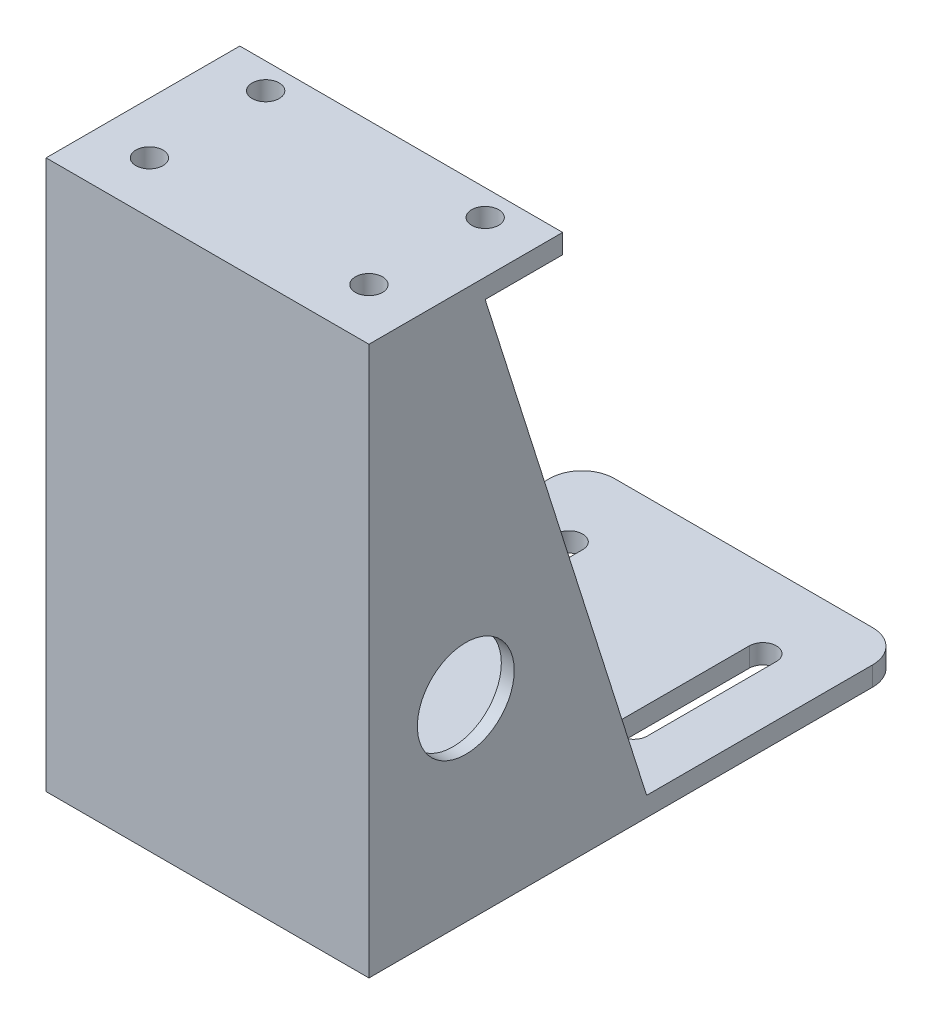
from build123d import *

# Parameters (mm, degrees)
EXTRUDE_1_DEPTH     = 25
EXTRUDE_2_DEPTH     = 2
CUT_EXTRUDE_1_REACH = 87
SKETCH_4_R          = 2.1
CUT_EXTRUDE_2_REACH = 87
FILLET_1_R          = 5
EXTRUDE_3_DEPTH     = 2
SKETCH_7_R          = 7.5
CUT_EXTRUDE_3_DEPTH = 51


with BuildPart() as part:
    # 草图1 → 凸台-拉伸1 (new body, symmetric)
    with BuildSketch(Plane(origin=(0, 0, 0), x_dir=(0, 0, -1), z_dir=(1, 0, 0))):
        Polygon((0, 0), (0, 85), (30, 85), (30, 82), (3, 82), (3, 3), (83, 3), (83, 0), align=None)
    extrude(amount=EXTRUDE_1_DEPTH, both=True)

    # 草图2 → 凸台-拉伸2 (add)
    with BuildSketch(Plane(origin=(25, 0, 0), x_dir=(0, 0, -1), z_dir=(1, 0, 0))):
        Polygon((43, 3), (3, 3), (3, 82), (18, 82), align=None)
    extrude(amount=-EXTRUDE_2_DEPTH)

    # 草图4 → 切除-拉伸1 (cut, up to next)
    with BuildSketch(Plane(origin=(0, 85, 0), x_dir=(1, 0, 0), z_dir=(0, 1, 0)), mode=Mode.PRIVATE) as cut_extrude_1_sk1:
        with Locations((-17, 26)):
            Circle(SKETCH_4_R)
    cut_extrude_1_tool1 = extrude(cut_extrude_1_sk1.sketch, amount=-CUT_EXTRUDE_1_REACH, mode=Mode.PRIVATE) & part.part
    add(cut_extrude_1_tool1.solids().sort_by_distance((-17, 85, -26))[0], mode=Mode.SUBTRACT)
    # 草图4 → 切除-拉伸1 (cut, up to next)
    with BuildSketch(Plane(origin=(0, 85, 0), x_dir=(1, 0, 0), z_dir=(0, 1, 0)), mode=Mode.PRIVATE) as cut_extrude_1_sk2:
        with Locations((-17, 8)):
            Circle(SKETCH_4_R)
    cut_extrude_1_tool2 = extrude(cut_extrude_1_sk2.sketch, amount=-CUT_EXTRUDE_1_REACH, mode=Mode.PRIVATE) & part.part
    add(cut_extrude_1_tool2.solids().sort_by_distance((-17, 85, -8))[0], mode=Mode.SUBTRACT)
    # 草图4 → 切除-拉伸1 (cut, up to next)
    with BuildSketch(Plane(origin=(0, 85, 0), x_dir=(1, 0, 0), z_dir=(0, 1, 0)), mode=Mode.PRIVATE) as cut_extrude_1_sk3:
        with Locations((17, 8)):
            Circle(SKETCH_4_R)
    cut_extrude_1_tool3 = extrude(cut_extrude_1_sk3.sketch, amount=-CUT_EXTRUDE_1_REACH, mode=Mode.PRIVATE) & part.part
    add(cut_extrude_1_tool3.solids().sort_by_distance((17, 85, -8))[0], mode=Mode.SUBTRACT)
    # 草图4 → 切除-拉伸1 (cut, up to next)
    with BuildSketch(Plane(origin=(0, 85, 0), x_dir=(1, 0, 0), z_dir=(0, 1, 0)), mode=Mode.PRIVATE) as cut_extrude_1_sk4:
        with Locations((17, 26)):
            Circle(SKETCH_4_R)
    cut_extrude_1_tool4 = extrude(cut_extrude_1_sk4.sketch, amount=-CUT_EXTRUDE_1_REACH, mode=Mode.PRIVATE) & part.part
    add(cut_extrude_1_tool4.solids().sort_by_distance((17, 85, -26))[0], mode=Mode.SUBTRACT)

    # 草图5 → 切除-拉伸2 (cut, up to next)
    with BuildSketch(Plane.XZ, mode=Mode.PRIVATE) as cut_extrude_2_sk1:
        with BuildLine():
            Line((-12.9, -11), (-12.9, -31))
            ThreePointArc((-12.9, -31), (-15, -33.1), (-17.1, -31))
            Line((-17.1, -31), (-17.1, -11))
            ThreePointArc((-17.1, -11), (-15, -8.9), (-12.9, -11))
        make_face()
    cut_extrude_2_tool1 = extrude(cut_extrude_2_sk1.sketch, amount=-CUT_EXTRUDE_2_REACH, mode=Mode.PRIVATE) & part.part
    add(cut_extrude_2_tool1.solids().sort_by_distance((-15, 0, -21))[0], mode=Mode.SUBTRACT)
    # 草图5 → 切除-拉伸2 (cut, up to next)
    with BuildSketch(Plane.XZ, mode=Mode.PRIVATE) as cut_extrude_2_sk2:
        with BuildLine():
            Line((-12.9, -51), (-12.9, -71))
            ThreePointArc((-12.9, -71), (-15, -73.1), (-17.1, -71))
            Line((-17.1, -71), (-17.1, -51))
            ThreePointArc((-17.1, -51), (-15, -48.9), (-12.9, -51))
        make_face()
    cut_extrude_2_tool2 = extrude(cut_extrude_2_sk2.sketch, amount=-CUT_EXTRUDE_2_REACH, mode=Mode.PRIVATE) & part.part
    add(cut_extrude_2_tool2.solids().sort_by_distance((-15, 0, -61))[0], mode=Mode.SUBTRACT)
    # 草图5 → 切除-拉伸2 (cut, up to next)
    with BuildSketch(Plane.XZ, mode=Mode.PRIVATE) as cut_extrude_2_sk3:
        with BuildLine():
            Line((12.9, -51), (12.9, -71))
            ThreePointArc((12.9, -71), (15, -73.1), (17.1, -71))
            Line((17.1, -71), (17.1, -51))
            ThreePointArc((17.1, -51), (15, -48.9), (12.9, -51))
        make_face()
    cut_extrude_2_tool3 = extrude(cut_extrude_2_sk3.sketch, amount=-CUT_EXTRUDE_2_REACH, mode=Mode.PRIVATE) & part.part
    add(cut_extrude_2_tool3.solids().sort_by_distance((15, 0, -61))[0], mode=Mode.SUBTRACT)
    # 草图5 → 切除-拉伸2 (cut, up to next)
    with BuildSketch(Plane.XZ, mode=Mode.PRIVATE) as cut_extrude_2_sk4:
        with BuildLine():
            Line((12.9, -11), (12.9, -31))
            ThreePointArc((12.9, -31), (15, -33.1), (17.1, -31))
            Line((17.1, -31), (17.1, -11))
            ThreePointArc((17.1, -11), (15, -8.9), (12.9, -11))
        make_face()
    cut_extrude_2_tool4 = extrude(cut_extrude_2_sk4.sketch, amount=-CUT_EXTRUDE_2_REACH, mode=Mode.PRIVATE) & part.part
    add(cut_extrude_2_tool4.solids().sort_by_distance((15, 0, -21))[0], mode=Mode.SUBTRACT)

    # 圆角1
    fillet_1_edges = [part.edges().sort_by_distance(p)[0] for p in [
        (-25, 1.5, -83),
        (25, 1.5, -83),
    ]]
    fillet(fillet_1_edges, radius=FILLET_1_R)

    # 草图6 → 凸台-拉伸3 (add)
    with BuildSketch(Plane.ZY.offset(25)):
        Polygon((-43, 3), (-3, 3), (-3, 82), (-18, 82), align=None)
    extrude(amount=-EXTRUDE_3_DEPTH)

    # 草图7 → 切除-拉伸3 (cut, through all)
    with BuildSketch(Plane(origin=(25, 0, 0), x_dir=(0, 0, -1), z_dir=(1, 0, 0))):
        with Locations((15, 30)):
            Circle(SKETCH_7_R)
    extrude(amount=-CUT_EXTRUDE_3_DEPTH, mode=Mode.SUBTRACT)


solid = part.part
